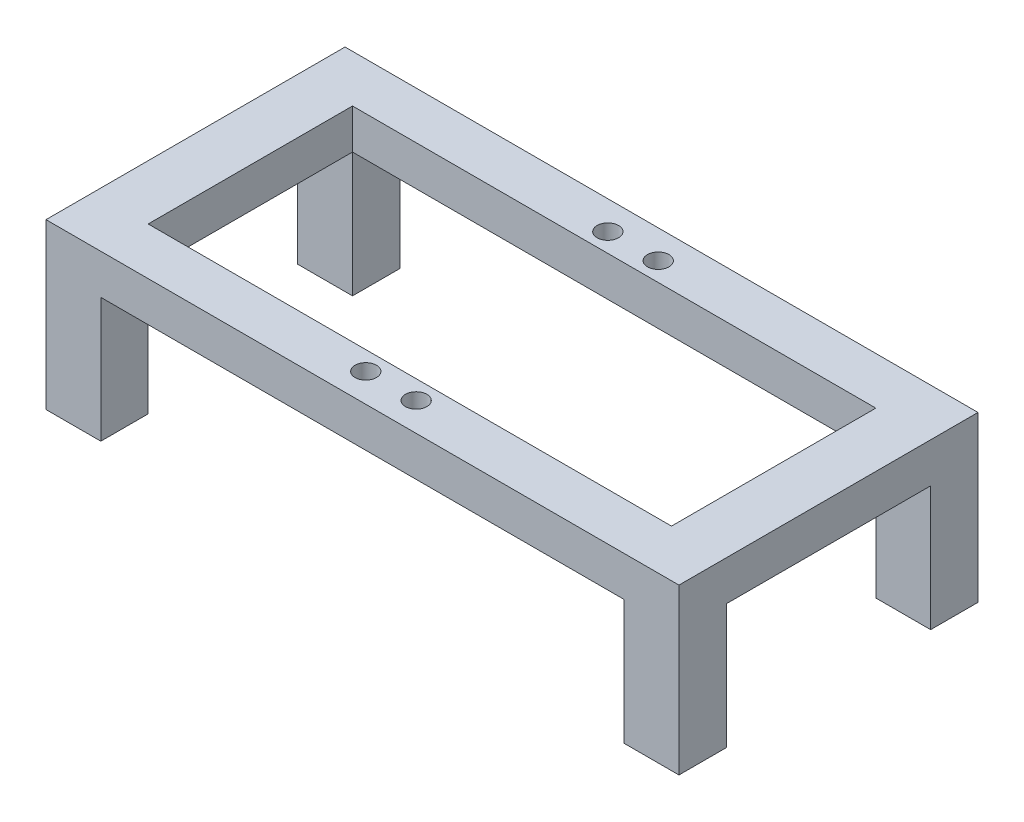
from build123d import *

# Parameters (mm, degrees)
SKETCH2_W           = 127
SKETCH2_H           = 60
SKETCH2_W_2         = 105
SKETCH2_H_2         = 41
BOSS_EXTRUDE2_DEPTH = 8
SKETCH3_R           = 2.15
CUT_EXTRUDE1_DEPTH  = 5.159375
SKETCH4_W           = 11
SKETCH4_H           = 9.5
BOSS_EXTRUDE3_DEPTH = 25


with BuildPart() as part:
    # Sketch2 → Boss-Extrude2 (new body)
    with BuildSketch(Plane(origin=(0, 0, 0), x_dir=(1, 0, 0), z_dir=(0, 1, 0))):
        Rectangle(SKETCH2_W, SKETCH2_H)
        Rectangle(SKETCH2_W_2, SKETCH2_H_2, mode=Mode.SUBTRACT)
    extrude(amount=-BOSS_EXTRUDE2_DEPTH)

    # Sketch3 → Cut-Extrude1 (cut)
    with BuildSketch(Plane(origin=(0, 0, 0), x_dir=(1, 0, 0), z_dir=(0, 1, 0))):
        with Locations((5.055, -24.285)):
            Circle(SKETCH3_R)
        with Locations((-5.055, 24.285)):
            Circle(SKETCH3_R)
        with Locations((5.055, 24.285)):
            Circle(SKETCH3_R)
        with Locations((-5.055, -24.285)):
            Circle(SKETCH3_R)
    extrude(amount=-CUT_EXTRUDE1_DEPTH, mode=Mode.SUBTRACT)

    # Sketch4 → Boss-Extrude3 (add)
    with BuildSketch(Plane.XZ.offset(8)):
        with Locations((-58, 25.25)):
            Rectangle(SKETCH4_W, SKETCH4_H)
        with Locations((58, 25.25)):
            Rectangle(SKETCH4_W, SKETCH4_H)
        with Locations((58, -25.25)):
            Rectangle(SKETCH4_W, SKETCH4_H)
        with Locations((-58, -25.25)):
            Rectangle(SKETCH4_W, SKETCH4_H)
    extrude(amount=BOSS_EXTRUDE3_DEPTH)


solid = part.part
